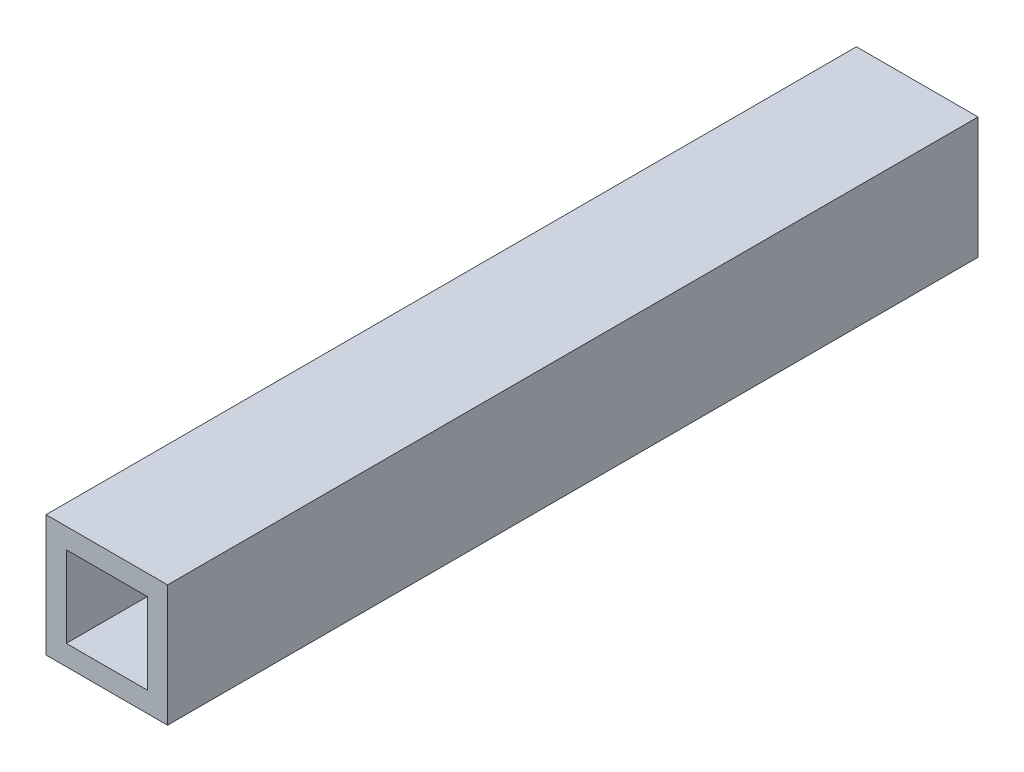
from build123d import *

# Parameters (mm, degrees)
SKETCH1_W           = 19.05
SKETCH1_H           = 19.05
BOSS_EXTRUDE1_DEPTH = 127
CUT_EXTRUDE1_REACH  = 129
SKETCH2_W           = 12.7
SKETCH2_H           = 12.7


with BuildPart() as part:
    # Sketch1 → Boss-Extrude1 (new body)
    with BuildSketch(Plane.XY):
        Rectangle(SKETCH1_W, SKETCH1_H)
    extrude(amount=-BOSS_EXTRUDE1_DEPTH)

    # Sketch2 → Cut-Extrude1 (cut, up to next)
    with BuildSketch(Plane.XY, mode=Mode.PRIVATE) as cut_extrude1_sk1:
        Rectangle(SKETCH2_W, SKETCH2_H)
    cut_extrude1_tool1 = extrude(cut_extrude1_sk1.sketch, amount=-CUT_EXTRUDE1_REACH, mode=Mode.PRIVATE) & part.part
    add(cut_extrude1_tool1.solids().sort_by_distance((0, 0, 0))[0], mode=Mode.SUBTRACT)


solid = part.part
